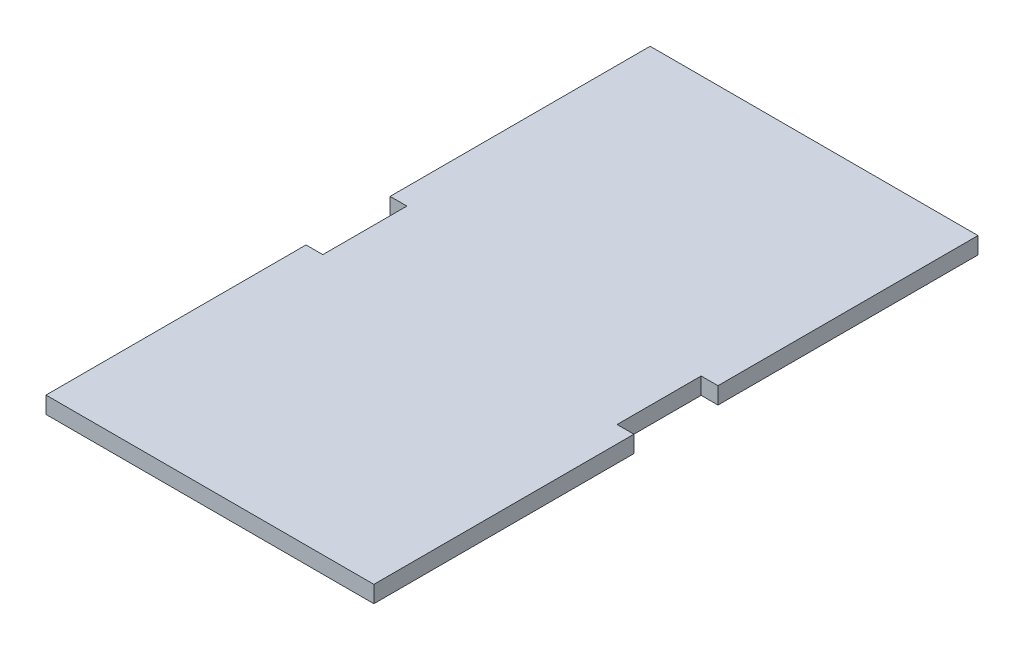
from build123d import *

# Parameters (mm, degrees)
SKETCH1_W           = 88.9
SKETCH1_H           = 182.5244
SKETCH1_W_2         = 5.08
SKETCH1_H_2         = 78.5622
BOSS_EXTRUDE1_DEPTH = 5.08


with BuildPart() as part:
    # Sketch1 → Boss-Extrude1 (new body)
    with BuildSketch(Plane(origin=(0, 0, 0), x_dir=(1, 0, 0), z_dir=(0, 1, 0))):
        Rectangle(SKETCH1_W, SKETCH1_H)
        with Locations((-46.99, 51.9811)):
            Rectangle(SKETCH1_W_2, SKETCH1_H_2)
        with Locations((-46.99, -51.9811)):
            Rectangle(SKETCH1_W_2, SKETCH1_H_2)
        with Locations((46.99, -51.9811)):
            Rectangle(SKETCH1_W_2, SKETCH1_H_2)
        with Locations((46.99, 51.9811)):
            Rectangle(SKETCH1_W_2, SKETCH1_H_2)
    extrude(amount=BOSS_EXTRUDE1_DEPTH)


solid = part.part
